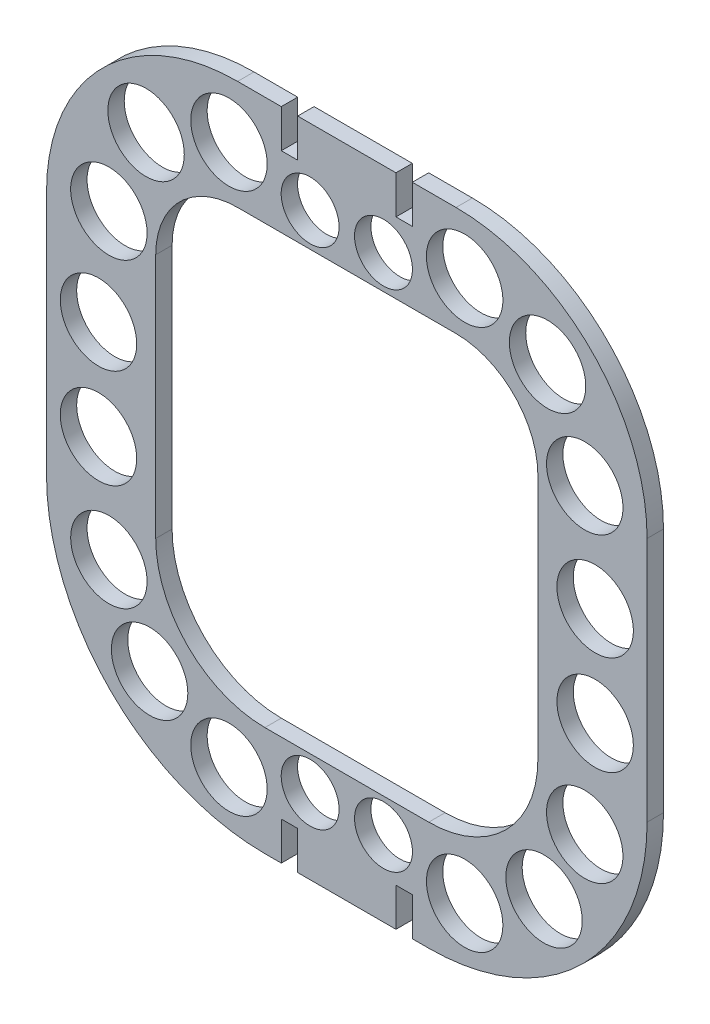
from build123d import *

# Parameters (mm, degrees)
BOSS_EXTRUDE1_DEPTH = 3
SKETCH2_W           = 3
SKETCH2_H           = 7
CUT_EXTRUDE1_DEPTH  = 10
SKETCH3_R           = 7
SKETCH3_R_2         = 5.302946182
CUT_EXTRUDE2_DEPTH  = 10


with BuildPart() as part:
    # Sketch1 → Boss-Extrude1 (new body)
    with BuildSketch(Plane.XY):
        with BuildLine():
            Line((-20, 52), (20, 52))
            ThreePointArc((20, 52), (44.748737342, 41.748737342), (55, 17))
            Line((55, 17), (55, -28))
            ThreePointArc((55, -28), (43.284271247, -56.284271247), (15, -68))
            Line((15, -68), (0.5, -68))
            Line((0.5, -68), (-0.5, -68))
            Line((-0.5, -68), (-15, -68))
            ThreePointArc((-15, -68), (-43.284271247, -56.284271247), (-55, -28))
            Line((-55, -28), (-55, 17))
            ThreePointArc((-55, 17), (-44.748737342, 41.748737342), (-20, 52))
        make_face()
        with BuildLine():
            Line((-20, 32), (20, 32))
            ThreePointArc((20, 32), (30.606601718, 27.606601718), (35, 17))
            Line((35, 17), (35, -28))
            ThreePointArc((35, -28), (29.142135624, -42.142135624), (15, -48))
            Line((15, -48), (0.5, -48))
            Line((0.5, -48), (-0.5, -48))
            Line((-0.5, -48), (-15, -48))
            ThreePointArc((-15, -48), (-29.142135624, -42.142135624), (-35, -28))
            Line((-35, -28), (-35, 17))
            ThreePointArc((-35, 17), (-30.606601718, 27.606601718), (-20, 32))
        make_face(mode=Mode.SUBTRACT)
    extrude(amount=BOSS_EXTRUDE1_DEPTH)

    # Sketch2 → Cut-Extrude1 (cut)
    with BuildSketch(Plane.XY.offset(3)):
        with Locations((-10.5, 48.5)):
            Rectangle(SKETCH2_W, SKETCH2_H)
        with Locations((-10.5, -64.5)):
            Rectangle(SKETCH2_W, SKETCH2_H)
        with Locations((10.5, -64.5)):
            Rectangle(SKETCH2_W, SKETCH2_H)
        with Locations((10.5, 48.5)):
            Rectangle(SKETCH2_W, SKETCH2_H)
    extrude(amount=-CUT_EXTRUDE1_DEPTH, mode=Mode.SUBTRACT)

    # Sketch3 → Cut-Extrude2 (cut)
    with BuildSketch(Plane.XY.offset(3)):
        with Locations((-45.481132216, 1.090233118)):
            Circle(SKETCH3_R)
        with Locations((-43.578653483, 19.639400767)):
            Circle(SKETCH3_R)
        with Locations((-36.768644381, 35.507802928)):
            Circle(SKETCH3_R)
        with Locations((-21.58124313, 41.57195389)):
            Circle(SKETCH3_R)
        with Locations((-6.718128027, 38.188568416)):
            Circle(SKETCH3_R_2)
        with Locations((-6.718128027, -54.188568416)):
            Circle(SKETCH3_R_2)
        with Locations((-21.58124313, -57.57195389)):
            Circle(SKETCH3_R)
        with Locations((-43.578653483, -35.639400767)):
            Circle(SKETCH3_R)
        with Locations((-45.481132216, -17.090233118)):
            Circle(SKETCH3_R)
        with Locations((45.481132216, -17.090233118)):
            Circle(SKETCH3_R)
        with Locations((43.578653483, -35.639400767)):
            Circle(SKETCH3_R)
        with Locations((21.58124313, -57.57195389)):
            Circle(SKETCH3_R)
        with Locations((6.718128027, -54.188568416)):
            Circle(SKETCH3_R_2)
        with Locations((6.718128027, 38.188568416)):
            Circle(SKETCH3_R_2)
        with Locations((21.58124313, 41.57195389)):
            Circle(SKETCH3_R)
        with Locations((36.768644381, 35.507802928)):
            Circle(SKETCH3_R)
        with Locations((43.578653483, 19.639400767)):
            Circle(SKETCH3_R)
        with Locations((45.481132216, 1.090233118)):
            Circle(SKETCH3_R)
        with Locations((-36.120072086, -49.624208078)):
            Circle(SKETCH3_R)
        with Locations((36.120072086, -49.624208078)):
            Circle(SKETCH3_R)
    extrude(amount=-CUT_EXTRUDE2_DEPTH, mode=Mode.SUBTRACT)


solid = part.part
